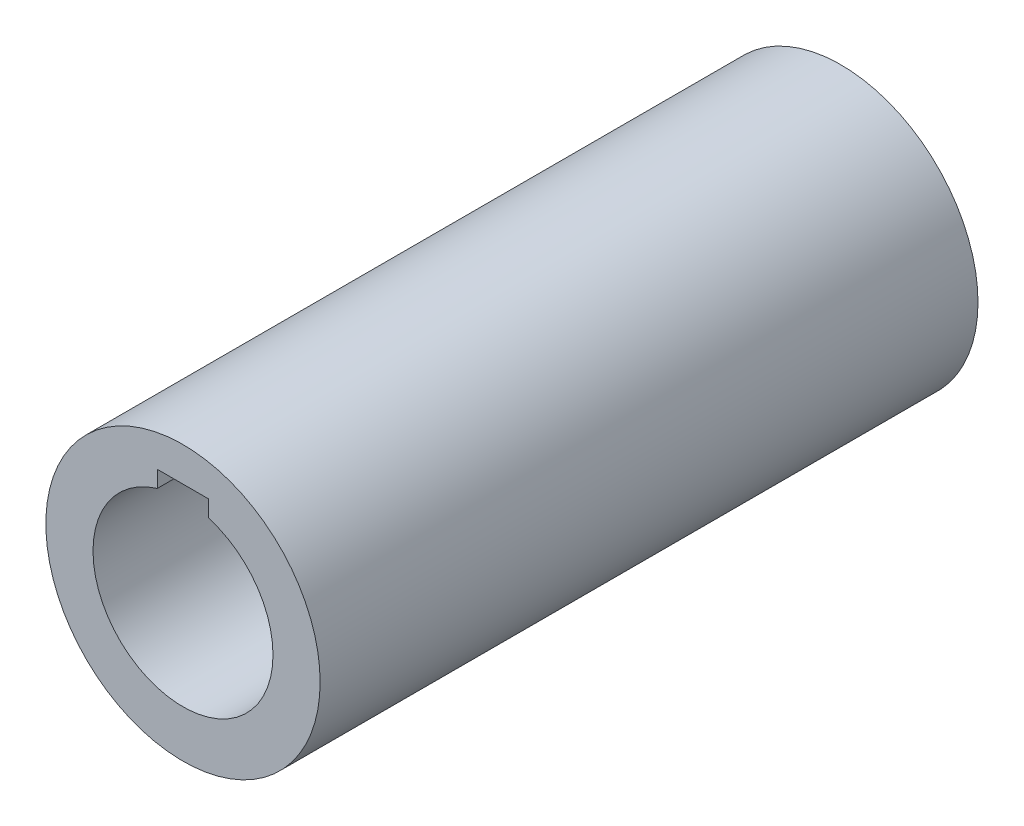
from build123d import *

# Parameters (mm, degrees)
SKETCH1_R           = 32
SKETCH1_R_2         = 21
BOSS_EXTRUDE1_DEPTH = 153.5
SKETCH2_W           = 12
SKETCH2_H           = 3.875388203
CUT_EXTRUDE1_DEPTH  = 154.5


with BuildPart() as part:
    # Sketch1 → Boss-Extrude1 (new body)
    with BuildSketch(Plane.XY):
        Circle(SKETCH1_R)
        Circle(SKETCH1_R_2, mode=Mode.SUBTRACT)
    extrude(amount=BOSS_EXTRUDE1_DEPTH)

    # Sketch2 → Cut-Extrude1 (cut, through all)
    with BuildSketch(Plane.XY.offset(153.5)):
        with Locations((0, 22.062305899)):
            Rectangle(SKETCH2_W, SKETCH2_H)
    extrude(amount=-CUT_EXTRUDE1_DEPTH, mode=Mode.SUBTRACT)


solid = part.part
